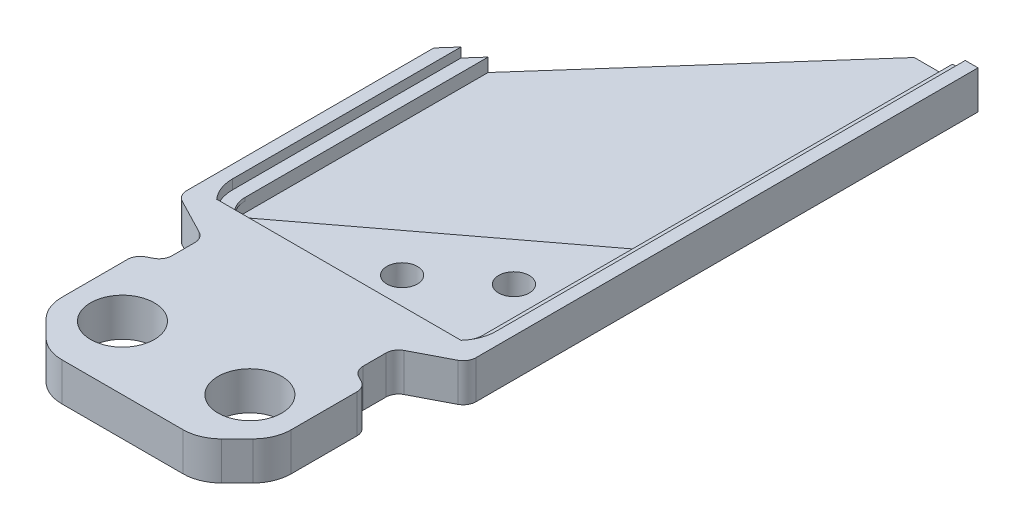
from build123d import *

# Parameters (mm, degrees)
BOSS_EXTRUDE1_DEPTH                             = 1.5
SKETCH2_R                                       = 2.5
CUT_EXTRUDE1_DEPTH                              = 2.5
CUT_EXTRUDE1_DEPTH_BACK                         = 2.5
SKETCH4_W                                       = 18.7
SKETCH4_H                                       = 38.8
CUT_EXTRUDE4_DEPTH                              = 2.5
SKETCH4_2_W                                     = 18.7
SKETCH4_2_H                                     = 38.8
CUT_EXTRUDE5_DEPTH                              = 0.3
FILLET6_R                                       = 2
SKETCH4_4_W                                     = 18.7
SKETCH4_4_H                                     = 38.8
CUT_EXTRUDE6_DEPTH                              = 0.5
CUT_EXTRUDE6_DEPTH_BACK                         = 0.3
BOSS_EXTRUDE2_DEPTH                             = 0.8
FILLET7_R                                       = 2
CHAMFER1_SIZE                                   = 3
FILLET2_R                                       = 1
FILLET3_R                                       = 3
CUT_EXTRUDE7_DEPTH                              = 0.75
CSK_FOR_M2_FLAT_HEAD_MACHINE_SCREW1_D           = 2.4
CSK_FOR_M2_FLAT_HEAD_MACHINE_SCREW1_DEPTH       = 4
CSK_FOR_M2_FLAT_HEAD_MACHINE_SCREW1_CSINK_D     = 4.4
CSK_FOR_M2_FLAT_HEAD_MACHINE_SCREW1_CSINK_ANGLE = 90
CSK_FOR_M2_FLAT_HEAD_MACHINE_SCREW1_TIP         = 0.721032743


with BuildPart() as part:
    # Sketch1 → Boss-Extrude1 (new body, symmetric)
    with BuildSketch(Plane(origin=(0, 0, 0), x_dir=(1, 0, 0), z_dir=(0, 1, 0))):
        Polygon((-9, 0), (-9, 10), (-7.5, 10.779220779), (-7.5, 13.779220779), (-11.35, 15.779220779), (-11.35, 35.779220779), (6.35, 55.779220779), (11.35, 55.779220779), (11.35, 15.779220779), (7.5, 13.779220779), (7.5, 10.779220779), (9, 10), (9, 0), align=None)
    extrude(amount=BOSS_EXTRUDE1_DEPTH, both=True)

    # Sketch2 → Cut-Extrude1 (cut, two sides)
    with BuildSketch(Plane(origin=(0, 0, 0), x_dir=(1, 0, 0), z_dir=(0, 1, 0))) as cut_extrude1_sk:
        with Locations((-5, 5)):
            Circle(SKETCH2_R)
        with Locations((5, 5)):
            Circle(SKETCH2_R)
    extrude(amount=CUT_EXTRUDE1_DEPTH, mode=Mode.SUBTRACT)
    extrude(cut_extrude1_sk.sketch, amount=-CUT_EXTRUDE1_DEPTH_BACK, mode=Mode.SUBTRACT)

    # Sketch4 → Cut-Extrude4 (cut, through all)
    with BuildSketch(Plane(origin=(0, 0, 0), x_dir=(1, 0, 0), z_dir=(0, 1, 0))):
        with Locations((0, 36.379220779)):
            Rectangle(SKETCH4_W, SKETCH4_H)
    extrude(amount=CUT_EXTRUDE4_DEPTH, mode=Mode.SUBTRACT)

    # Sketch4_2 → Cut-Extrude5 (cut, symmetric)
    with BuildSketch(Plane(origin=(0, 0, 0), x_dir=(1, 0, 0), z_dir=(0, 1, 0))):
        with Locations((0, 36.379220779)):
            Rectangle(SKETCH4_2_W, SKETCH4_2_H)
    extrude(amount=CUT_EXTRUDE5_DEPTH, both=True, mode=Mode.SUBTRACT)

    # Fillet6
    fillet6_edges = [part.edges().sort_by_distance(p)[0] for p in [
        (-9.35, 0.6, -16.979220779),
    ]]
    fillet(fillet6_edges, radius=FILLET6_R)

    # Sketch4_4 → Cut-Extrude6 (cut, two sides)
    with BuildSketch(Plane(origin=(0, 0, 0), x_dir=(1, 0, 0), z_dir=(0, 1, 0))) as cut_extrude6_sk:
        with Locations((0, 36.379220779)):
            Rectangle(SKETCH4_4_W, SKETCH4_4_H)
    extrude(amount=CUT_EXTRUDE6_DEPTH, mode=Mode.SUBTRACT)
    extrude(cut_extrude6_sk.sketch, amount=-CUT_EXTRUDE6_DEPTH_BACK, mode=Mode.SUBTRACT)

    # Sketch9 → Boss-Extrude2 (add)
    with BuildSketch(Plane(origin=(0, -0.3, 0), x_dir=(1, 0, 0), z_dir=(0, 1, 0))):
        Polygon((9.35, 16.979220779), (9.35, 31.104220779), (-7.35, 18.489915966), (-9.35, 16.979220779), align=None)
    extrude(amount=BOSS_EXTRUDE2_DEPTH)

    # Fillet7
    fillet7_edges = [part.edges().sort_by_distance(p)[0] for p in [
        (9.35, 1, -16.979220779),
    ]]
    fillet(fillet7_edges, radius=FILLET7_R)

    # Chamfer1
    chamfer1_edges = [part.edges().sort_by_distance(p)[0] for p in [
        (-9, 0, 0),
        (9, 0, 0),
    ]]
    chamfer(chamfer1_edges, length=CHAMFER1_SIZE)

    # Fillet2
    fillet2_edges = [part.edges().sort_by_distance(p)[0] for p in [
        (-9, 0, -10),
        (-7.5, 0, -10.779220779),
        (-7.5, 0, -13.779220779),
        (-11.35, 0, -15.779220779),
        (11.35, 0, -15.779220779),
        (7.5, 0, -13.779220779),
        (7.5, 0, -10.779220779),
        (9, 0, -10),
    ]]
    fillet(fillet2_edges, radius=FILLET2_R)

    # Fillet3
    fillet3_edges = [part.edges().sort_by_distance(p)[0] for p in [
        (9, 0, -3),
        (-6, 0, 0),
        (6, 0, 0),
        (-9, 0, -3),
    ]]
    fillet(fillet3_edges, radius=FILLET3_R)

    # Sketch10 → Cut-Extrude7 (cut)
    with BuildSketch(Plane(origin=(0, 1.5, 0), x_dir=(1, 0, 0), z_dir=(0, 1, 0))):
        with BuildLine():
            Line((-10.35, 36.909164283), (-10.35, 18.97922078))
            ThreePointArc((-10.35, 18.97922078), (-10.152517077, 17.908754511), (-9.586067977, 16.97922078))
            Line((-9.586067977, 16.97922078), (9.586067977, 16.97922078))
            ThreePointArc((9.586067977, 16.97922078), (10.152517077, 17.908754511), (10.35, 18.97922078))
            Line((10.35, 18.97922078), (10.35, 55.77922078))
            Line((10.35, 55.77922078), (6.35, 55.77922078))
            Line((6.35, 55.77922078), (-10.35, 36.909164283))
        make_face()
    extrude(amount=-CUT_EXTRUDE7_DEPTH, mode=Mode.SUBTRACT)

    # CSK for M2 Flat Head Machine Screw1
    with Locations(Plane(origin=(-5, 1.5, 32.5), x_dir=(1, 0, 0), z_dir=(0, 1, 0))):
        with Locations((11.85, 56.367589763), (6.85, 52.590851795)):
            CounterSinkHole(CSK_FOR_M2_FLAT_HEAD_MACHINE_SCREW1_D / 2, CSK_FOR_M2_FLAT_HEAD_MACHINE_SCREW1_CSINK_D / 2, depth=CSK_FOR_M2_FLAT_HEAD_MACHINE_SCREW1_DEPTH, counter_sink_angle=CSK_FOR_M2_FLAT_HEAD_MACHINE_SCREW1_CSINK_ANGLE)
            with Locations((0, 0, -(CSK_FOR_M2_FLAT_HEAD_MACHINE_SCREW1_DEPTH + CSK_FOR_M2_FLAT_HEAD_MACHINE_SCREW1_TIP / 2))):  # 118° drill point
                Cone(0, CSK_FOR_M2_FLAT_HEAD_MACHINE_SCREW1_D / 2, CSK_FOR_M2_FLAT_HEAD_MACHINE_SCREW1_TIP, mode=Mode.SUBTRACT)


solid = part.part
